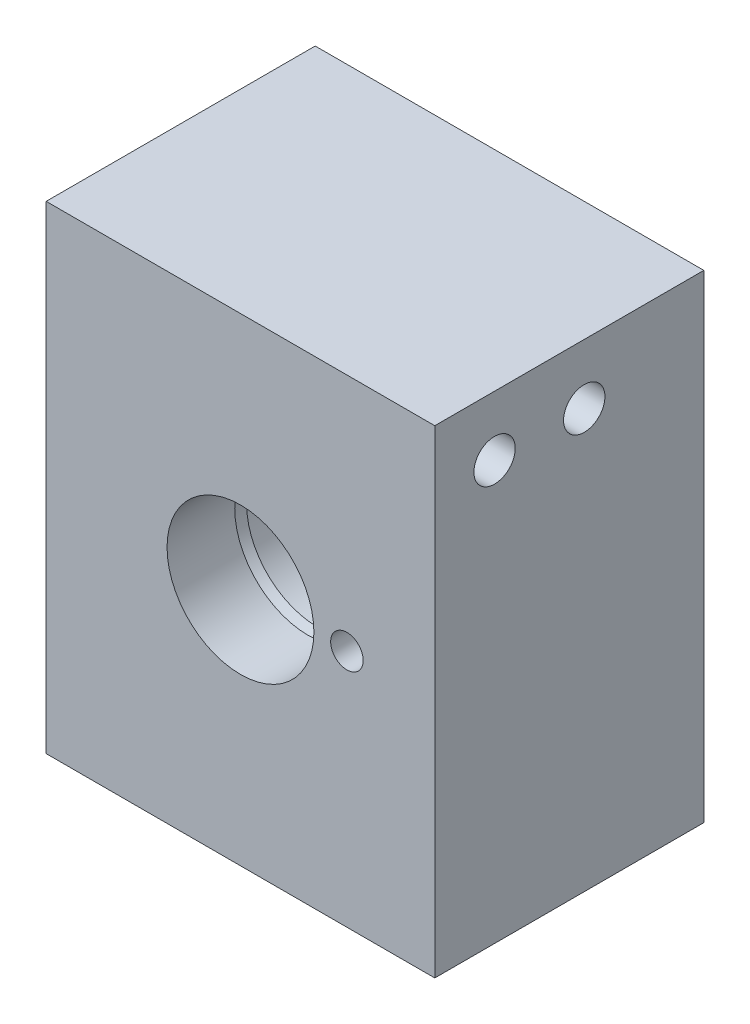
from build123d import *

# Parameters (mm, degrees)
SKETCH7_W                       = 41.275
SKETCH7_H                       = 28.575
BOSS_EXTRUDE2_DEPTH             = 50.8
SKETCH31_R                      = 9.525
CUT_EXTRUDE1_DEPTH              = 6.35
FILLET3_R                       = 0.127
F_8_32_TAPPED_HOLE1_D           = 3.4544
F_8_32_TAPPED_HOLE1_DEPTH       = 10.16
F_8_32_TAPPED_HOLE1_TIP         = 1.037806461
F_17_0_173_DIAMETER_HOLE1_D     = 4.3942
F_46_0_081_DIAMETER_HOLE1_D     = 2.0574
F_46_0_081_DIAMETER_HOLE1_DEPTH = 19.066894681
F_46_0_081_DIAMETER_HOLE1_TIP   = 0.618105319


with BuildPart() as part:
    # Sketch7 → Boss-Extrude2 (new body)
    with BuildSketch(Plane(origin=(0, 0, 0), x_dir=(1, 0, 0), z_dir=(0, 1, 0))):
        with Locations((-1.5875, -7.9375)):
            Rectangle(SKETCH7_W, SKETCH7_H)
    extrude(amount=BOSS_EXTRUDE2_DEPTH)

    # Sketch31 → Cut-Extrude1 (cut)
    with BuildSketch(Plane(origin=(0, 0, -6.35), x_dir=(-1, 0, 0), z_dir=(0, 0, -1))):
        with Locations((1.5875, 25.4)):
            Circle(SKETCH31_R)
    extrude(amount=-CUT_EXTRUDE1_DEPTH, mode=Mode.SUBTRACT)

    # Sketch24 → Port Manifold (revolve, cut)
    with BuildSketch(Plane.ZY.offset(1.5875)):
        with BuildLine():
            Line((22.225, 25.4), (22.225, 33.1978))
            Line((22.225, 33.1978), (15.0368, 33.1978))
            Line((15.0368, 33.1978), (14.04146205, 32.9311))
            Line((14.04146205, 32.9311), (8.2804, 32.9311))
            ThreePointArc((8.2804, 32.9311), (8.136715902, 32.871584098), (8.0772, 32.7279))
            Line((8.0772, 32.7279), (8.0772, 29.2735))
            Line((8.0772, 29.2735), (7.637259095, 29.0195))
            Line((7.637259095, 29.0195), (4.7752, 29.0195))
            ThreePointArc((4.7752, 29.0195), (4.631515902, 28.959984098), (4.572, 28.8163))
            Line((4.572, 28.8163), (4.572, 26.034032808))
            Line((4.572, 26.034032808), (3.111576387, 26.04897))
            Line((3.111576387, 26.04897), (-0.714966433, 28.258225527))
            Line((-0.714966433, 28.258225527), (-0.714966433, 25.4))
            Line((-0.714966433, 25.4), (22.225, 25.4))
        make_face()
    revolve(axis=Axis((-1.5875, 25.4, -0.714966433), (0, 0, 1)), mode=Mode.SUBTRACT)

    # Fillet3
    fillet3_edges = [part.edges().sort_by_distance(p)[0] for p in [
        (-1.5875, 24.765967192, 4.572),
    ]]
    fillet(fillet3_edges, radius=FILLET3_R)

    # #8-32 Tapped Hole1
    with Locations(Plane.XY.offset(22.225)):
        with Locations((9.7155, 25.4)):
            Hole(F_8_32_TAPPED_HOLE1_D / 2, depth=F_8_32_TAPPED_HOLE1_DEPTH)
            with Locations((0, 0, -(F_8_32_TAPPED_HOLE1_DEPTH + F_8_32_TAPPED_HOLE1_TIP / 2))):  # 118° drill point
                Cone(0, F_8_32_TAPPED_HOLE1_D / 2, F_8_32_TAPPED_HOLE1_TIP, mode=Mode.SUBTRACT)

    # Sketch29 → 1/8 NPT Tapped Hole1 (revolve, cut)
    with BuildSketch(Plane(origin=(-1.5875, 0, 7.9375), x_dir=(0, 0, -1), z_dir=(1, 0, 0))):
        Polygon((0, 0), (0, 14.217468714), (4.2164, 11.684), (4.2164, 6.858), (4.537401096, 6.858), (4.7427388, 0), align=None)
    revolve(axis=Axis((-1.5875, -6.35, 7.9375), (0, 1, 0)), mode=Mode.SUBTRACT)

    # #17 (0.173) Diameter Hole1 (through all)
    with Locations(Plane.ZY.offset(22.225)):
        with Locations((6.35, 44.45), (15.875, 44.45)):
            Hole(F_17_0_173_DIAMETER_HOLE1_D / 2)

    # #46 (0.081) Diameter Hole1
    with Locations(Plane(origin=(0, 0, 0), x_dir=(-1, 0, 0), z_dir=(0, -1, 0))):
        with Locations((1.5875, -7.9375)):
            Hole(F_46_0_081_DIAMETER_HOLE1_D / 2, depth=F_46_0_081_DIAMETER_HOLE1_DEPTH)
            with Locations((0, 0, -(F_46_0_081_DIAMETER_HOLE1_DEPTH + F_46_0_081_DIAMETER_HOLE1_TIP / 2))):  # 118° drill point
                Cone(0, F_46_0_081_DIAMETER_HOLE1_D / 2, F_46_0_081_DIAMETER_HOLE1_TIP, mode=Mode.SUBTRACT)


solid = part.part
